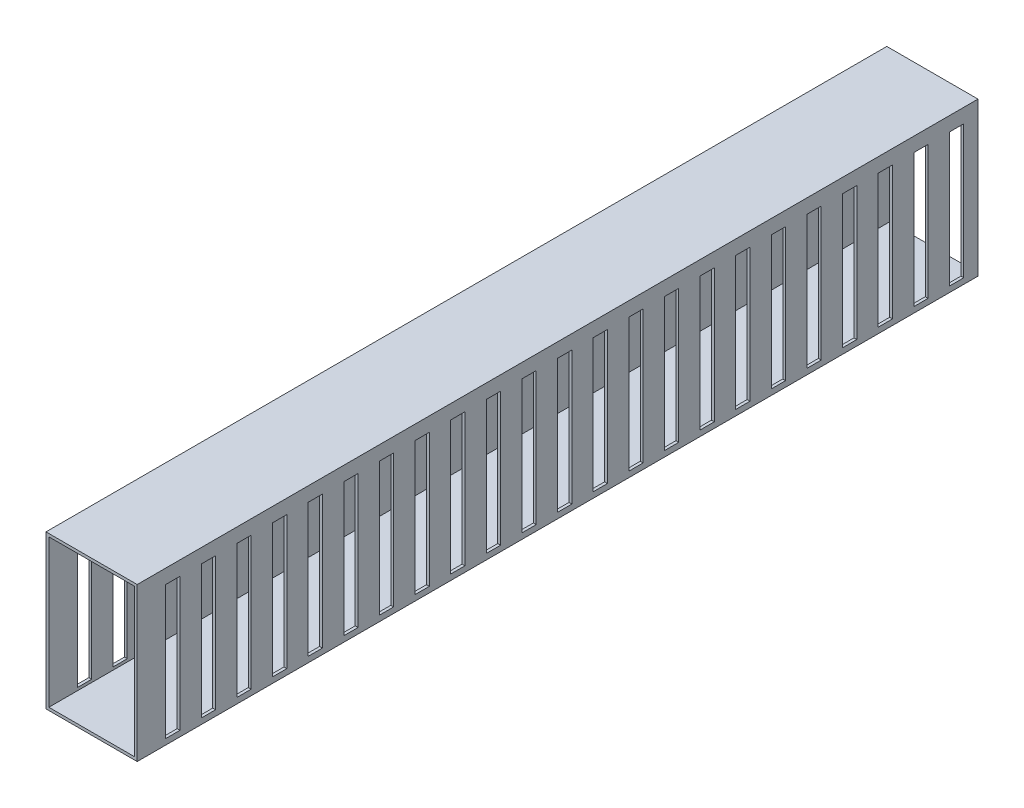
from build123d import *

# Parameters (mm, degrees)
ESQUISSE1_W                = 32
ESQUISSE1_H                = 53.8
ESQUISSE1_W_2              = 30
ESQUISSE1_H_2              = 51.8
BOSS_EXTRU_1_DEPTH         = 295
ESQUISSE2_W                = 5
ESQUISSE2_H                = 46.8
ENL_V_MAT_EXTRU_1_DEPTH    = 32
R_P_TITION_LIN_AIRE1_COUNT = 23
R_P_TITION_LIN_AIRE1_PITCH = 12.5


with BuildPart() as part:
    # Esquisse1 → Boss.-Extru.1 (new body)
    with BuildSketch(Plane.XY):
        with Locations((2.977116986, 10.236099585)):
            Rectangle(ESQUISSE1_W, ESQUISSE1_H)
        with Locations((2.977116986, 10.236099585)):
            Rectangle(ESQUISSE1_W_2, ESQUISSE1_H_2, mode=Mode.SUBTRACT)
    extrude(amount=BOSS_EXTRU_1_DEPTH)

    # Esquisse2 → Enlèv. mat.-Extru.1 (cut)
    with BuildSketch(Plane(origin=(18.977116986, 0, 0), x_dir=(0, 0, -1), z_dir=(1, 0, 0))):
        with Locations((-7.5, 8.736099585)):
            Rectangle(ESQUISSE2_W, ESQUISSE2_H)
    enl_v_mat_extru_1 = extrude(amount=-ENL_V_MAT_EXTRU_1_DEPTH, mode=Mode.SUBTRACT)

    # Répétition linéaire1: Enlèv. mat.-Extru.1 ×23
    with Locations(*[(0, 0, i * R_P_TITION_LIN_AIRE1_PITCH) for i in range(1, R_P_TITION_LIN_AIRE1_COUNT)]):
        add(enl_v_mat_extru_1, mode=Mode.SUBTRACT)


solid = part.part
